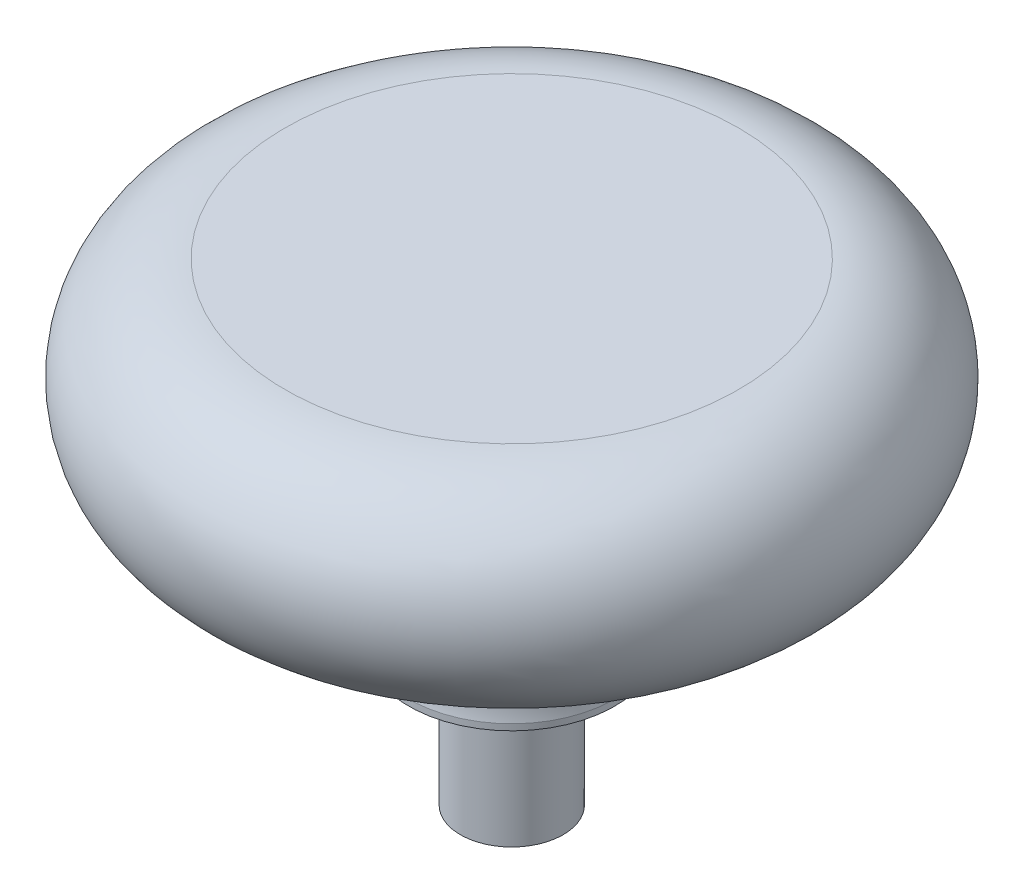
from build123d import *


with BuildPart() as part:
    # Sketch1 → Revolve1 (revolve)
    with BuildSketch(Plane.XY):
        with BuildLine():
            Line((0, 0), (2.38, 0))
            Line((2.38, 0), (2.38, 6.35))
            Line((2.38, 6.35), (4.77, 6.35))
            Line((4.77, 6.35), (4.77, 6.635226112))
            ThreePointArc((4.77, 6.635226112), (5.668747391, 10.685686779), (9.4, 12.5))
            ThreePointArc((9.4, 12.5), (15.237749216, 16.587689011), (10.5, 21.911432968))
            Line((10.5, 21.911432968), (0, 21.911432968))
            Line((0, 21.911432968), (0, 0))
        make_face()
    revolve(axis=Axis((0, 0, 0), (0, 1, 0)))


solid = part.part
